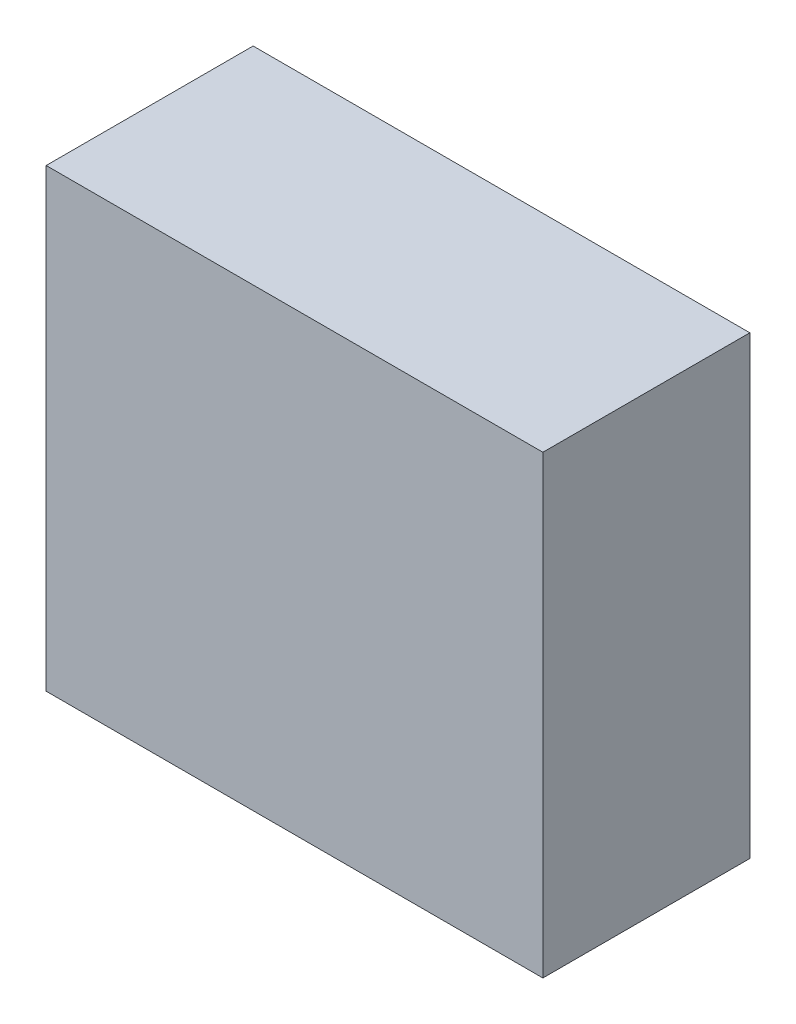
from build123d import *

# Parameters (mm, degrees)
SKETCH1_W           = 152.4
SKETCH1_H           = 139.7
BOSS_EXTRUDE1_DEPTH = 63.5


with BuildPart() as part:
    # Sketch1 → Boss-Extrude1 (new body)
    with BuildSketch(Plane.XY):
        Rectangle(SKETCH1_W, SKETCH1_H)
    extrude(amount=BOSS_EXTRUDE1_DEPTH)


solid = part.part
